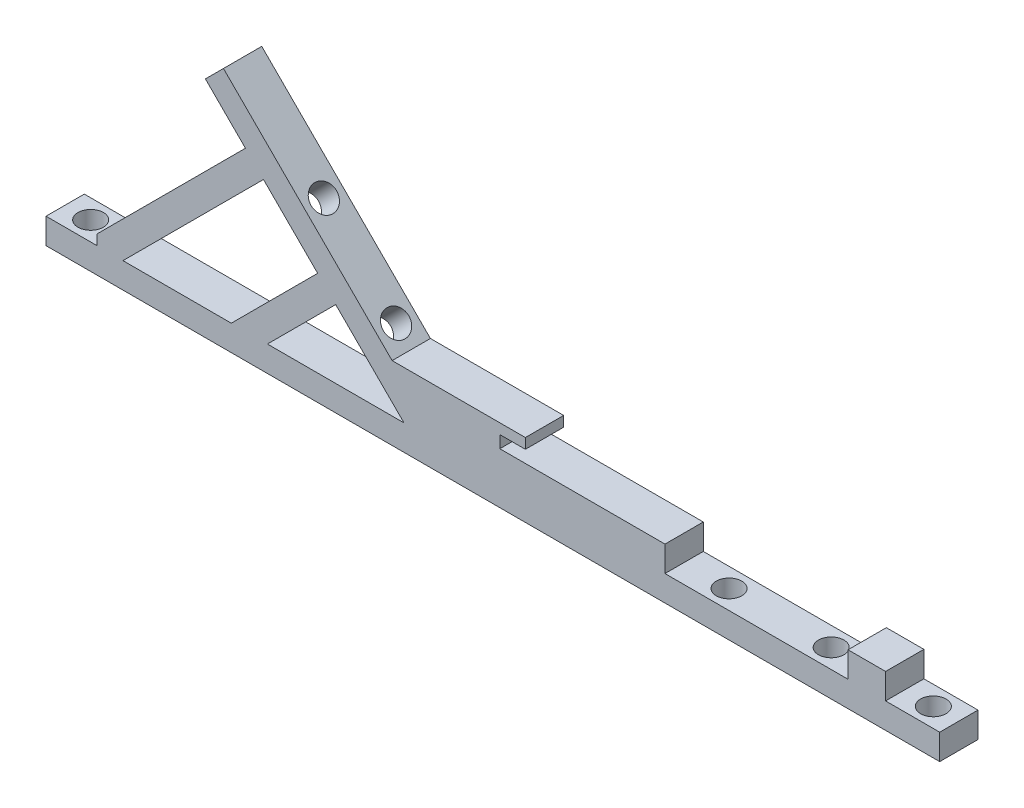
from build123d import *

# Parameters (mm, degrees)
SKETCH1_W           = 85.725
SKETCH1_H           = 4.7625
SKETCH1_R           = 1.5875
BOSS_EXTRUDE1_DEPTH = 3.175
BOSS_EXTRUDE2_DEPTH = 4.7625
CUT_EXTRUDE1_REACH  = 38.898
SKETCH3_R           = 1.5875
SKETCH4_W           = 4.7625
SKETCH4_H           = 3.175
BOSS_EXTRUDE3_DEPTH = 25.4
SKETCH5_R           = 1.5875
CUT_EXTRUDE2_DEPTH  = 4.175
SKETCH6_W           = 4.667184745
SKETCH6_H           = 3.175
BOSS_EXTRUDE4_DEPTH = 4.7625


with BuildPart() as part:
    # Sketch1 → Boss-Extrude1 (new body)
    with BuildSketch(Plane(origin=(0, 0, 0), x_dir=(1, 0, 0), z_dir=(0, 1, 0))):
        with Locations((-39.6875, 0)):
            Rectangle(SKETCH1_W, SKETCH1_H)
        Circle(SKETCH1_R, mode=Mode.SUBTRACT)
        with Locations((-79.375, 0)):
            Circle(SKETCH1_R, mode=Mode.SUBTRACT)
    extrude(amount=BOSS_EXTRUDE1_DEPTH)

    # Sketch2 → Boss-Extrude2 (add)
    with BuildSketch(Plane.XY.offset(2.38125)):
        Polygon((-5.58425135, 3.175), (-5.58425135, 6.35), (-26.118044342, 6.35), (-26.118044342, 7.874), (-22.943044342, 7.874), (-22.943044342, 9.144), (-39.512783425, 9.144), (-60.484551788, 30.115768363), (-62.729615818, 27.870704333), (-57.751955743, 22.893044257), (-76.185480906, 4.459519094), (-76.185480906, 3.175), (-72.979871939, 3.175), (-55.506891712, 20.647980227), (-48.771699622, 13.912788136), (-59.509487758, 3.175), (-55.019359697, 3.175), (-46.526635591, 11.667724106), (-38.033911485, 3.175), align=None)
    extrude(amount=-BOSS_EXTRUDE2_DEPTH)

    # Sketch3 → Cut-Extrude1 (cut, up to next)
    with BuildSketch(Plane(origin=(-15.184391712, -15.184391712, 0), x_dir=(0, 0, -1), z_dir=(0.707106781, 0.707106781, 0)), mode=Mode.PRIVATE) as cut_extrude1_sk1:
        with Locations((0, 49.776600757)):
            Circle(SKETCH3_R)
    cut_extrude1_tool1 = extrude(cut_extrude1_sk1.sketch, amount=-CUT_EXTRUDE1_REACH, mode=Mode.PRIVATE) & part.part
    add(cut_extrude1_tool1.solids().sort_by_distance((-50.381764, 20.01298, 0))[0], mode=Mode.SUBTRACT)
    # Sketch3 → Cut-Extrude1 (cut, up to next)
    with BuildSketch(Plane(origin=(-15.184391712, -15.184391712, 0), x_dir=(0, 0, -1), z_dir=(0.707106781, 0.707106781, 0)), mode=Mode.PRIVATE) as cut_extrude1_sk2:
        with Locations((0, 37.076600757)):
            Circle(SKETCH3_R)
    cut_extrude1_tool2 = extrude(cut_extrude1_sk2.sketch, amount=-CUT_EXTRUDE1_REACH, mode=Mode.PRIVATE) & part.part
    add(cut_extrude1_tool2.solids().sort_by_distance((-41.401508, 11.032724, 0))[0], mode=Mode.SUBTRACT)

    # Sketch4 → Boss-Extrude3 (add)
    with BuildSketch(Plane(origin=(3.175, 0, 0), x_dir=(0, 0, -1), z_dir=(1, 0, 0))):
        with Locations((0, 1.5875)):
            Rectangle(SKETCH4_W, SKETCH4_H)
    extrude(amount=BOSS_EXTRUDE3_DEPTH)

    # Sketch5 → Cut-Extrude2 (cut, through all)
    with BuildSketch(Plane(origin=(0, 3.175, 0), x_dir=(1, 0, 0), z_dir=(0, 1, 0))):
        with Locations((12.7, 0)):
            Circle(SKETCH5_R)
        with Locations((25.4, 0)):
            Circle(SKETCH5_R)
    extrude(amount=-CUT_EXTRUDE2_DEPTH, mode=Mode.SUBTRACT)

    # Sketch6 → Boss-Extrude4 (add)
    with BuildSketch(Plane.XY.offset(2.38125)):
        with Locations((19.512903732, 4.7625)):
            Rectangle(SKETCH6_W, SKETCH6_H)
    extrude(amount=-BOSS_EXTRUDE4_DEPTH)


solid = part.part
